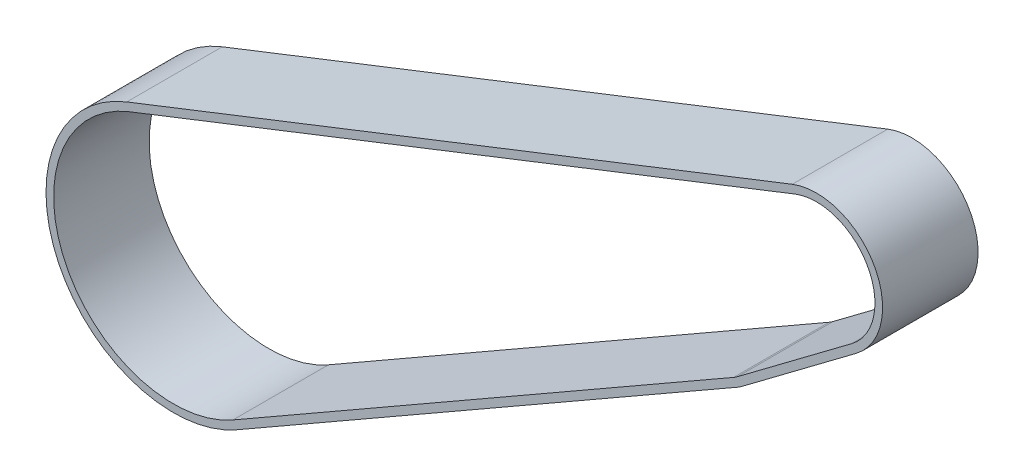
from build123d import *

# Parameters (mm, degrees)
EXTRUDE_THIN1_DEPTH = 15


with BuildPart() as part:
    # Sketch1 → Extrude-Thin1 (new body)
    with BuildSketch(Plane.XY):
        with BuildLine():
            Line((-348.568632332, -44.990241022), (-330.651704705, -31.544642204))
            ThreePointArc((-330.651704705, -31.544642204), (-327.814467779, -18.166031706), (-340.690762012, -13.557541818))
            Line((-340.690762012, -13.557541818), (-445.203365451, -54.61645429))
            ThreePointArc((-445.203365451, -54.61645429), (-455.920370474, -81.886807993), (-427.939056891, -90.580051229))
            Line((-427.939056891, -90.580051229), (-349.307825521, -45.476953187))
            ThreePointArc((-349.307825521, -45.476953187), (-348.930743386, -45.244965756), (-348.568632332, -44.990241022))
        make_face()
        with BuildLine():
            Line((-349.288903256, -44.030444275), (-331.371975629, -30.584845457))
            ThreePointArc((-331.371975629, -30.584845457), (-328.862311331, -18.750859791), (-340.251975557, -14.674442193))
            Line((-340.251975557, -14.674442193), (-444.764578996, -55.733354665))
            ThreePointArc((-444.764578996, -55.733354665), (-454.838563718, -81.367487146), (-428.53612895, -89.539135787))
            Line((-428.53612895, -89.539135787), (-349.90489758, -44.436037745))
            ThreePointArc((-349.90489758, -44.436037745), (-349.590662467, -44.242714886), (-349.288903256, -44.030444275))
        make_face(mode=Mode.SUBTRACT)
    extrude(amount=EXTRUDE_THIN1_DEPTH)


solid = part.part
